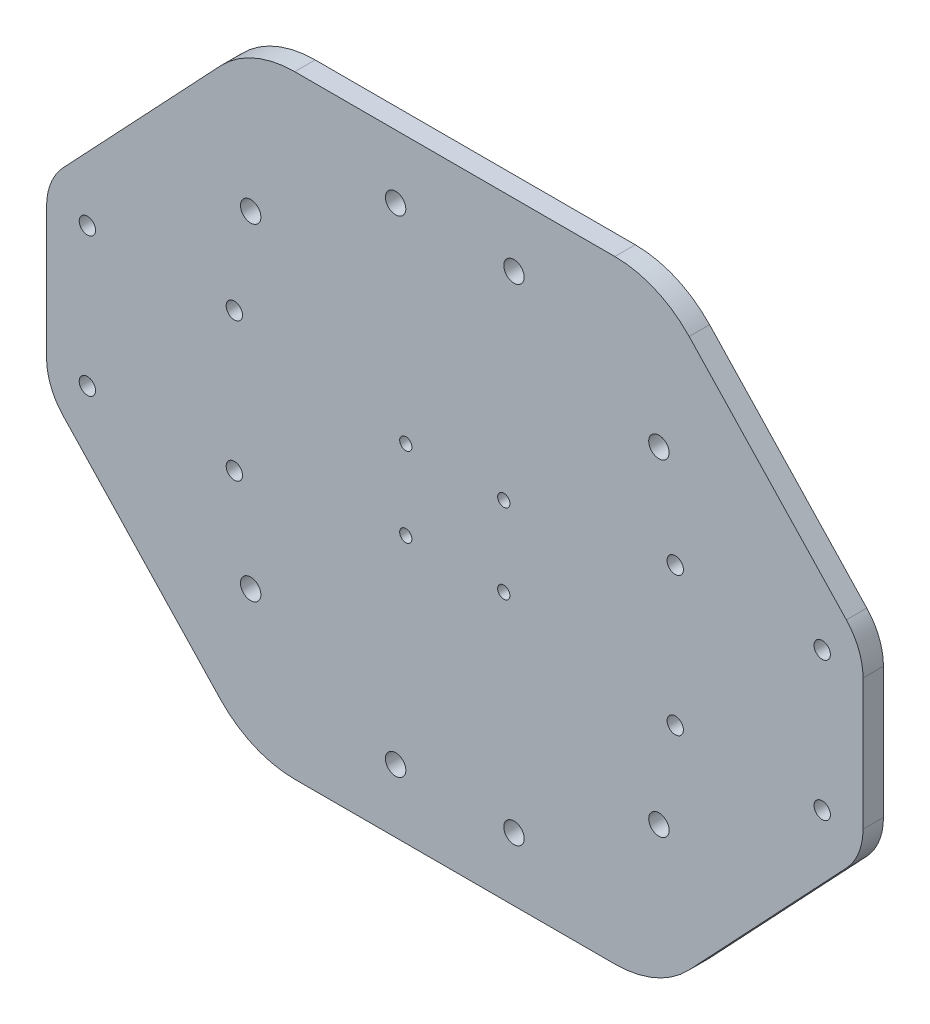
from build123d import *

# Parameters (mm, degrees)
CROQUIS1_W              = 200
CROQUIS1_H              = 150.1
CROQUIS1_R              = 2.5
SALIENTE_EXTRUIR1_DEPTH = 5
CROQUIS2_R              = 1.5
CROQUIS2_R_2            = 2
CORTAR_EXTRUIR1_DEPTH   = 10
CORTAR_EXTRUIR2_DEPTH   = 400


with BuildPart() as part:
    # Croquis1 → Saliente-Extruir1 (new body)
    with BuildSketch(Plane.XY):
        with Locations((100, 5.648844896)):
            Rectangle(CROQUIS1_W, CROQUIS1_H)
        with Locations((85.5, 65.198844896)):
            Circle(CROQUIS1_R, mode=Mode.SUBTRACT)
        with Locations((114.5, 65.198844896)):
            Circle(CROQUIS1_R, mode=Mode.SUBTRACT)
        with Locations((50, 45.698844896)):
            Circle(CROQUIS1_R, mode=Mode.SUBTRACT)
        with Locations((150, 45.698844896)):
            Circle(CROQUIS1_R, mode=Mode.SUBTRACT)
        with Locations((150, -34.401155104)):
            Circle(CROQUIS1_R, mode=Mode.SUBTRACT)
        with Locations((114.5, -53.901155104)):
            Circle(CROQUIS1_R, mode=Mode.SUBTRACT)
        with Locations((85.5, -53.901155104)):
            Circle(CROQUIS1_R, mode=Mode.SUBTRACT)
        with Locations((50, -34.401155104)):
            Circle(CROQUIS1_R, mode=Mode.SUBTRACT)
    extrude(amount=SALIENTE_EXTRUIR1_DEPTH)

    # Croquis2 → Cortar-Extruir1 (cut)
    with BuildSketch(Plane.XY.offset(5)):
        with Locations((88, 15.398844896)):
            Circle(CROQUIS2_R)
        with Locations((112, 15.398844896)):
            Circle(CROQUIS2_R)
        with Locations((88, -4.101155104)):
            Circle(CROQUIS2_R)
        with Locations((112, -4.101155104)):
            Circle(CROQUIS2_R)
        with Locations((10, 22.648844896)):
            Circle(CROQUIS2_R_2)
        with Locations((46, 22.648844896)):
            Circle(CROQUIS2_R_2)
        with Locations((46, -11.351155104)):
            Circle(CROQUIS2_R_2)
        with Locations((10, -11.351155104)):
            Circle(CROQUIS2_R_2)
        with Locations((190, -11.351155104)):
            Circle(CROQUIS2_R_2)
        with Locations((154, -11.351155104)):
            Circle(CROQUIS2_R_2)
        with Locations((154, 22.648844896)):
            Circle(CROQUIS2_R_2)
        with Locations((190, 22.648844896)):
            Circle(CROQUIS2_R_2)
    extrude(amount=-CORTAR_EXTRUIR1_DEPTH, mode=Mode.SUBTRACT)

    # Croquis3 → Cortar-Extruir2 (cut)
    with BuildSketch(Plane(origin=(0, 0, 0), x_dir=(-1, 0, 0), z_dir=(0, 0, -1))):
        with BuildLine():
            Line((-195.915748263, 31.98223599), (-157.401555296, 72.845794728))
            ThreePointArc((-157.401555296, 72.845794728), (-149.116372199, 78.651772224), (-139.208641525, 80.698844896))
            Line((-139.208641525, 80.698844896), (-200, 80.698844896))
            Line((-200, 80.698844896), (-200, 21.694066091))
            ThreePointArc((-200, 21.694066091), (-198.941596464, 27.2286743), (-195.915748263, 31.98223599))
        make_face()
        with BuildLine():
            Line((0, 80.698844896), (-60.791358475, 80.698844896))
            ThreePointArc((-60.791358475, 80.698844896), (-50.883627801, 78.651772224), (-42.598444704, 72.845794728))
            Line((-42.598444704, 72.845794728), (-4.084251737, 31.98223599))
            ThreePointArc((-4.084251737, 31.98223599), (-1.058403536, 27.2286743), (0, 21.694066091))
            Line((0, 21.694066091), (0, 80.698844896))
        make_face()
        with BuildLine():
            Line((0, -69.401155104), (0, -10.396376298))
            ThreePointArc((0, -10.396376298), (-1.058403536, -15.930984508), (-4.084251737, -20.684546197))
            Line((-4.084251737, -20.684546197), (-42.598444704, -61.548104935))
            ThreePointArc((-42.598444704, -61.548104935), (-50.883627801, -67.354082431), (-60.791358475, -69.401155104))
            Line((-60.791358475, -69.401155104), (0, -69.401155104))
        make_face()
        with BuildLine():
            ThreePointArc((-195.915748263, -20.684546197), (-198.941596464, -15.930984508), (-200, -10.396376298))
            Line((-200, -10.396376298), (-200, -69.401155104))
            Line((-200, -69.401155104), (-139.208641525, -69.401155104))
            ThreePointArc((-139.208641525, -69.401155104), (-149.116372199, -67.354082431), (-157.401555296, -61.548104935))
            Line((-157.401555296, -61.548104935), (-195.915748263, -20.684546197))
        make_face()
    extrude(amount=-CORTAR_EXTRUIR2_DEPTH, mode=Mode.SUBTRACT)


solid = part.part
